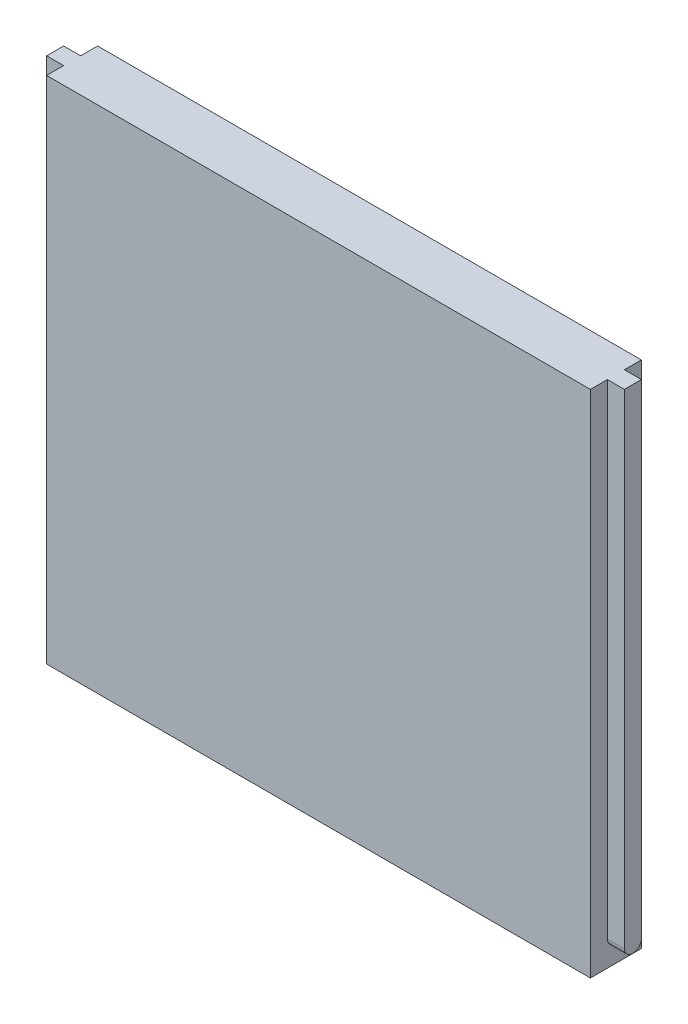
from build123d import *

# Parameters (mm, degrees)
SKETCH1_W           = 160
SKETCH1_H           = 150
BOSS_EXTRUDE1_DEPTH = 15
BOSS_EXTRUDE2_DEPTH = 5
CUT_EXTRUDE1_DEPTH  = 5


with BuildPart() as part:
    # Sketch1 → Boss-Extrude1 (new body)
    with BuildSketch(Plane.XY):
        with Locations((0, 8.754863813)):
            Rectangle(SKETCH1_W, SKETCH1_H)
    extrude(amount=BOSS_EXTRUDE1_DEPTH)

    # Sketch2 → Boss-Extrude2 (add)
    with BuildSketch(Plane(origin=(80, 0, 0), x_dir=(0, 0, -1), z_dir=(1, 0, 0))):
        with BuildLine():
            Line((-10, -58.745136187), (-10, 89.520228405))
            ThreePointArc((-10, 89.520228405), (-7.5, 92.020228405), (-5, 89.520228405))
            Line((-5, 89.520228405), (-5, -58.745136187))
            ThreePointArc((-5, -58.745136187), (-7.5, -61.245136187), (-10, -58.745136187))
        make_face()
    boss_extrude2 = extrude(amount=BOSS_EXTRUDE2_DEPTH)

    # Mirror1: Boss-Extrude2 across plane
    add(boss_extrude2.mirror(Plane(origin=(0, 0, 0), x_dir=(0, 0, 1), z_dir=(1, 0, 0))))

    # Sketch3 → Cut-Extrude1 (cut)
    with BuildSketch(Plane.ZY.offset(85)):
        with BuildLine():
            Line((5, 83.754863813), (10, 83.754863813))
            Line((10, 83.754863813), (10, 89.520228405))
            ThreePointArc((10, 89.520228405), (7.5, 92.020228405), (5, 89.520228405))
            Line((5, 89.520228405), (5, 83.754863813))
        make_face()
    cut_extrude1 = extrude(amount=-CUT_EXTRUDE1_DEPTH, mode=Mode.SUBTRACT)

    # Mirror2: Cut-Extrude1 across plane
    add(cut_extrude1.mirror(Plane(origin=(0, 0, 0), x_dir=(0, 0, 1), z_dir=(1, 0, 0))), mode=Mode.SUBTRACT)


solid = part.part
